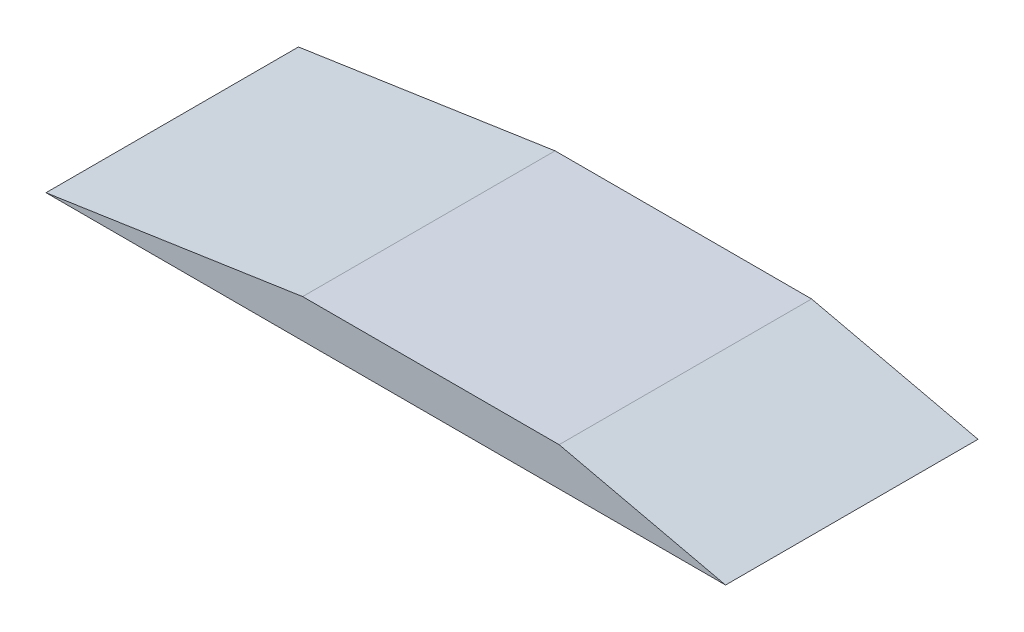
from build123d import *

# Parameters (mm, degrees)
EXTRUDE_1_DEPTH = 500


with BuildPart() as part:
    # 草图2 → 凸台-拉伸1 (new body)
    with BuildSketch(Plane.XY):
        Polygon((-95.000236101, -47.248362415), (921.313099911, -47.248362415), (1250.959349767, -47.248362415), (921.313099911, 28.700849047), (413.295633513, 28.700849047), align=None)
    extrude(amount=EXTRUDE_1_DEPTH)


solid = part.part
